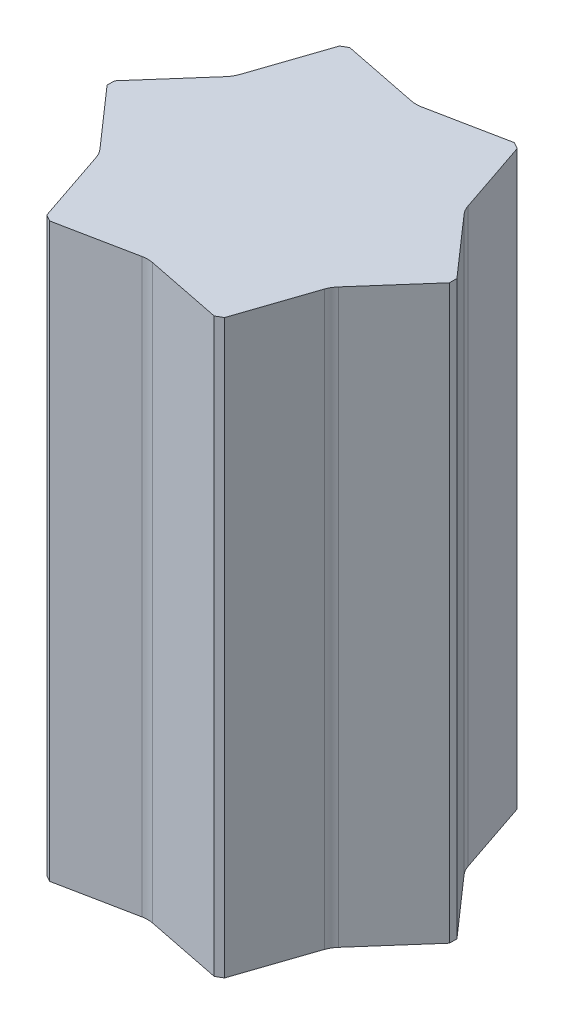
from build123d import *

# Parameters (mm, degrees)
EXTRUDE_1_DEPTH          = 660
CUT_EXTRUDE_1_DEPTH      = 661
CUT_EXTRUDE_1_DEPTH_BACK = 661


with BuildPart() as part:
    # 草图1 → 凸台-拉伸1 (new body, symmetric)
    with BuildSketch(Plane(origin=(0, 0, 0), x_dir=(1, 0, 0), z_dir=(0, 1, 0))):
        Polygon((395, 8.660254038), (205, 337.749907476), (190, 346.410161514), (-190, 346.410161514), (-205, 337.749907476), (-395, 8.660254038), (-395, -8.660254038), (-205, -337.749907476), (-190, -346.410161514), (190, -346.410161514), (205, -337.749907476), (395, -8.660254038), align=None)
    extrude(amount=EXTRUDE_1_DEPTH, both=True)

    # 草图4 → 切除-拉伸1 (cut, two sides)
    with BuildSketch(Plane(origin=(0, 0, 0), x_dir=(1, 0, 0), z_dir=(0, 1, 0))) as cut_extrude_1_sk:
        with BuildLine():
            Line((190, 369.620348729), (190, 346.410161514))
            Line((190, 346.410161514), (11.76, 310.784114995))
            ThreePointArc((11.76, 310.784114995), (0, 309.620348729), (-11.76, 310.784114995))
            Line((-11.76, 310.784114995), (-190, 346.410161514))
            Line((-190, 346.410161514), (-190, 369.620348729))
            Line((-190, 369.620348729), (-190, 392.830535944))
            Line((-190, 392.830535944), (-11.76, 428.456582463))
            ThreePointArc((-11.76, 428.456582463), (0, 429.620348729), (11.76, 428.456582463))
            Line((11.76, 428.456582463), (190, 392.830535944))
            Line((190, 392.830535944), (190, 369.620348729))
        make_face()
        with BuildLine():
            Line((415.100611755, 20.265347645), (395, 8.660254038))
            Line((395, 8.660254038), (275.026938678, 145.207598749))
            ThreePointArc((275.026938678, 145.207598749), (268.139087528, 154.810174364), (263.266938678, 165.576516246))
            Line((263.266938678, 165.576516246), (205, 337.749907476))
            Line((205, 337.749907476), (225.100611755, 349.355001084))
            Line((225.100611755, 349.355001084), (245.20122351, 360.960094691))
            Line((245.20122351, 360.960094691), (365.174284832, 224.41274998))
            ThreePointArc((365.174284832, 224.41274998), (372.062135982, 214.810174364), (376.934284832, 204.043832483))
            Line((376.934284832, 204.043832483), (435.20122351, 31.870441253))
            Line((435.20122351, 31.870441253), (415.100611755, 20.265347645))
        make_face()
        with BuildLine():
            Line((225.100611755, -349.355001084), (205, -337.749907476))
            Line((205, -337.749907476), (263.266938678, -165.576516246))
            ThreePointArc((263.266938678, -165.576516246), (268.139087528, -154.810174364), (275.026938678, -145.207598749))
            Line((275.026938678, -145.207598749), (395, -8.660254038))
            Line((395, -8.660254038), (415.100611755, -20.265347645))
            Line((415.100611755, -20.265347645), (435.20122351, -31.870441253))
            Line((435.20122351, -31.870441253), (376.934284832, -204.043832483))
            ThreePointArc((376.934284832, -204.043832483), (372.062135982, -214.810174364), (365.174284832, -224.41274998))
            Line((365.174284832, -224.41274998), (245.20122351, -360.960094691))
            Line((245.20122351, -360.960094691), (225.100611755, -349.355001084))
        make_face()
        with BuildLine():
            Line((-190, -369.620348729), (-190, -346.410161514))
            Line((-190, -346.410161514), (-11.76, -310.784114995))
            ThreePointArc((-11.76, -310.784114995), (0, -309.620348729), (11.76, -310.784114995))
            Line((11.76, -310.784114995), (190, -346.410161514))
            Line((190, -346.410161514), (190, -369.620348729))
            Line((190, -369.620348729), (190, -392.830535944))
            Line((190, -392.830535944), (11.76, -428.456582463))
            ThreePointArc((11.76, -428.456582463), (0, -429.620348729), (-11.76, -428.456582463))
            Line((-11.76, -428.456582463), (-190, -392.830535944))
            Line((-190, -392.830535944), (-190, -369.620348729))
        make_face()
        with BuildLine():
            Line((-415.100611755, -20.265347645), (-395, -8.660254038))
            Line((-395, -8.660254038), (-275.026938678, -145.207598749))
            ThreePointArc((-275.026938678, -145.207598749), (-268.139087528, -154.810174364), (-263.266938678, -165.576516246))
            Line((-263.266938678, -165.576516246), (-205, -337.749907476))
            Line((-205, -337.749907476), (-225.100611755, -349.355001084))
            Line((-225.100611755, -349.355001084), (-245.20122351, -360.960094691))
            Line((-245.20122351, -360.960094691), (-365.174284832, -224.41274998))
            ThreePointArc((-365.174284832, -224.41274998), (-372.062135982, -214.810174364), (-376.934284832, -204.043832483))
            Line((-376.934284832, -204.043832483), (-435.20122351, -31.870441253))
            Line((-435.20122351, -31.870441253), (-415.100611755, -20.265347645))
        make_face()
        with BuildLine():
            Line((-225.100611755, 349.355001084), (-205, 337.749907476))
            Line((-205, 337.749907476), (-263.266938678, 165.576516246))
            ThreePointArc((-263.266938678, 165.576516246), (-268.139087528, 154.810174364), (-275.026938678, 145.207598749))
            Line((-275.026938678, 145.207598749), (-395, 8.660254038))
            Line((-395, 8.660254038), (-415.100611755, 20.265347645))
            Line((-415.100611755, 20.265347645), (-435.20122351, 31.870441253))
            Line((-435.20122351, 31.870441253), (-376.934284832, 204.043832483))
            ThreePointArc((-376.934284832, 204.043832483), (-372.062135982, 214.810174364), (-365.174284832, 224.41274998))
            Line((-365.174284832, 224.41274998), (-245.20122351, 360.960094691))
            Line((-245.20122351, 360.960094691), (-225.100611755, 349.355001084))
        make_face()
    extrude(amount=CUT_EXTRUDE_1_DEPTH, mode=Mode.SUBTRACT)
    extrude(cut_extrude_1_sk.sketch, amount=-CUT_EXTRUDE_1_DEPTH_BACK, mode=Mode.SUBTRACT)


solid = part.part
